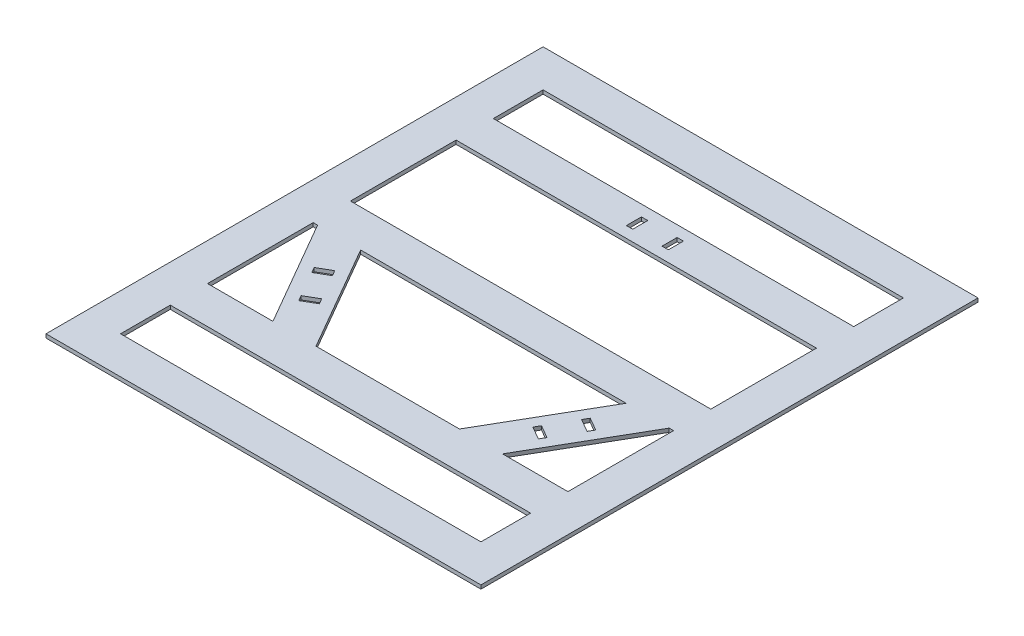
from build123d import *

# Parameters (mm, degrees)
CROQUIS1_W              = 350
CROQUIS1_H              = 400
CROQUIS1_W_2            = 290
CROQUIS1_H_2            = 340
CROQUIS1_H_3            = 30
SALIENTE_EXTRUIR1_DEPTH = 3
CROQUIS9_W              = 5.1
CROQUIS9_H              = 12.1
CORTAR_EXTRUIR3_DEPTH   = 4
MATRIZC2_COUNT          = 3


with BuildPart() as part:
    # Croquis1 → Saliente-Extruir1 (new body)
    with BuildSketch(Plane(origin=(0, 0, 0), x_dir=(1, 0, 0), z_dir=(0, 1, 0))):
        Rectangle(CROQUIS1_W, CROQUIS1_H)
        Rectangle(CROQUIS1_W_2, CROQUIS1_H_2, mode=Mode.SUBTRACT)
        with Locations((0, 115)):
            Rectangle(CROQUIS1_W_2, CROQUIS1_H_3)
        Polygon((-145, 15), (-145, -15), (-141.450815951, -15), (-106.8097998, -15), (106.8097998, -15), (141.450815951, -15), (145, -15), (145, 15), align=None)
        Polygon((-145, -100), (-145, -130), (145, -130), (145, -100), (92.37604307, -100), (57.735026919, -100), (-57.735026919, -100), (-92.37604307, -100), align=None)
        Polygon((-141.450815951, -15), (-92.37604307, -100), (-57.735026919, -100), (-106.8097998, -15), align=None)
        Polygon((57.735026919, -100), (92.37604307, -100), (141.450815951, -15), (106.8097998, -15), align=None)
    extrude(amount=SALIENTE_EXTRUIR1_DEPTH)

    # Croquis9 → Cortar-Extruir3 (cut, through all)
    with BuildSketch(Plane(origin=(0, 0, 0), x_dir=(1, 0, 0), z_dir=(0, 1, 0))):
        with Locations((-14.35, 115)):
            Rectangle(CROQUIS9_W, CROQUIS9_H)
        with Locations((14.35, 115)):
            Rectangle(CROQUIS9_W, CROQUIS9_H)
    cortar_extruir3 = extrude(amount=CORTAR_EXTRUIR3_DEPTH, mode=Mode.SUBTRACT)

    # MatrizC2: Cortar-Extruir3 ×3 about axis
    matrizc2_axis = Axis((0, 0, 0), (0, 1, 0))
    for i in range(1, MATRIZC2_COUNT):
        add(cortar_extruir3.rotate(matrizc2_axis, i * 360 / MATRIZC2_COUNT), mode=Mode.SUBTRACT)


solid = part.part
